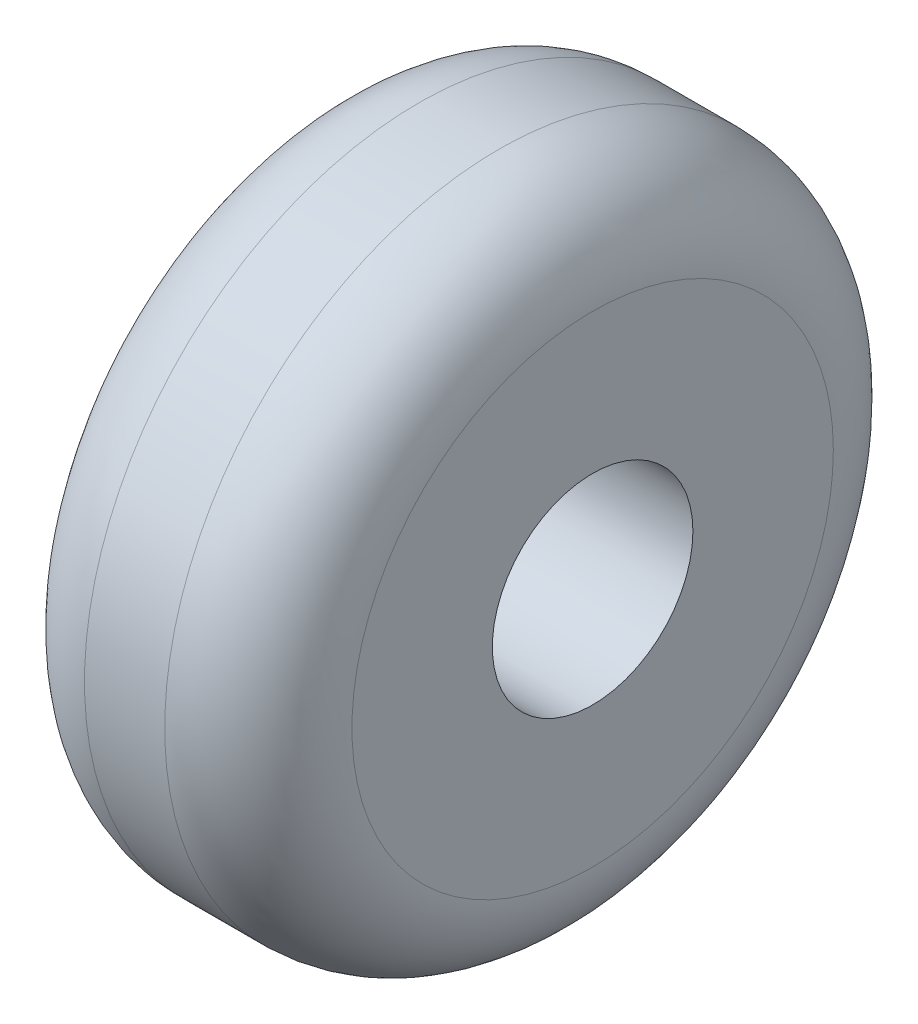
from build123d import *

# Parameters (mm, degrees)
SKETCH1_R           = 2.5
SKETCH1_R_2         = 0.75
BOSS_EXTRUDE1_DEPTH = 1
FILLET1_R           = 0.7


with BuildPart() as part:
    # Sketch1 → Boss-Extrude1 (new body, symmetric)
    with BuildSketch(Plane(origin=(0, 0, 0), x_dir=(0, 0, -1), z_dir=(1, 0, 0))):
        Circle(SKETCH1_R)
        Circle(SKETCH1_R_2, mode=Mode.SUBTRACT)
    extrude(amount=BOSS_EXTRUDE1_DEPTH, both=True)

    # Fillet1
    fillet1_edges = [part.edges().sort_by_distance(p)[0] for p in [
        (-1, 0, 2.5),
        (1, 0, 2.5),
    ]]
    fillet(fillet1_edges, radius=FILLET1_R)


solid = part.part
